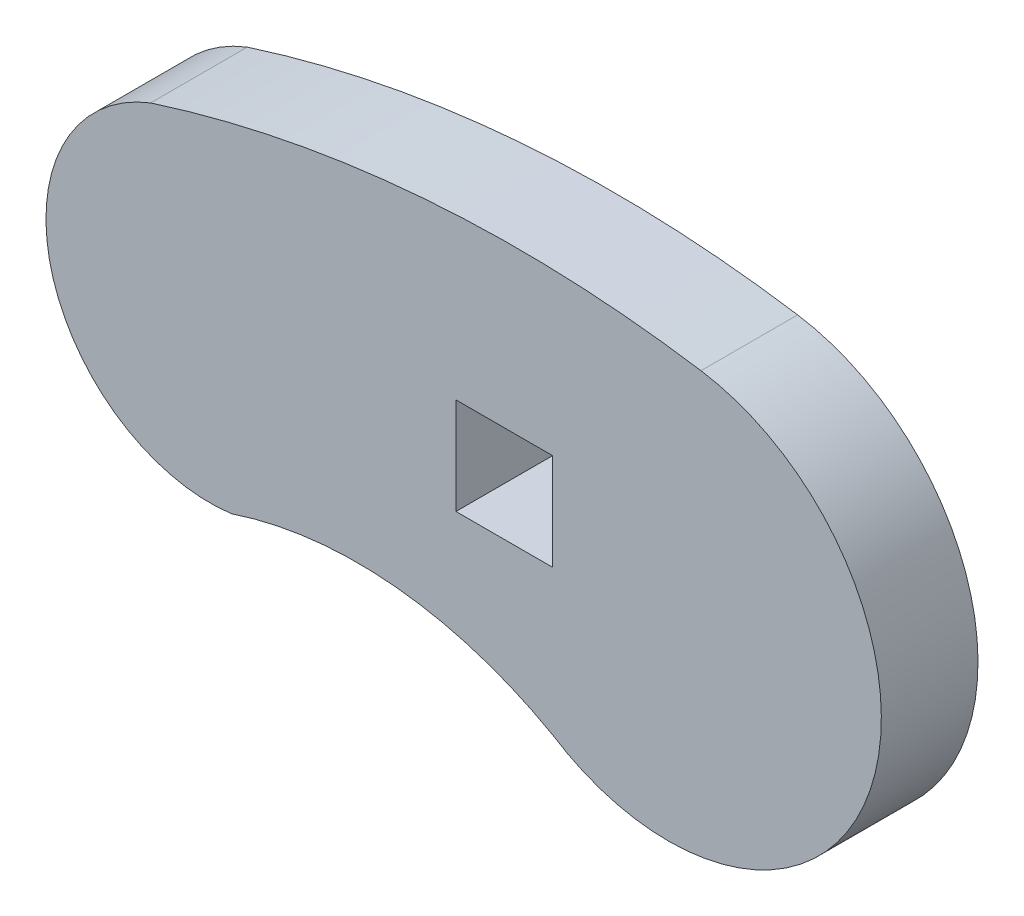
from build123d import *

# Parameters (mm, degrees)
SKETCH1_W           = 1.524
SKETCH1_H           = 1.524
BOSS_EXTRUDE1_DEPTH = 1.524


with BuildPart() as part:
    # Sketch1 → Boss-Extrude1 (new body)
    with BuildSketch(Plane.XY):
        with BuildLine():
            ThreePointArc((-4.813018271, 1.647414383), (-6.381436297, -1.405112195), (-3.535820464, -3.323529288))
            ThreePointArc((-3.535820464, -3.323529288), (-0.953914357, -3.028591374), (1.524, -3.811641797))
            ThreePointArc((1.524, -3.811641797), (6.486387953, -2.185545764), (3.86325293, 2.329832974))
            ThreePointArc((3.86325293, 2.329832974), (-0.514779052, 2.495866349), (-4.813018271, 1.647414383))
        make_face()
        with Locations((0.762, -0.762)):
            Rectangle(SKETCH1_W, SKETCH1_H, mode=Mode.SUBTRACT)
    extrude(amount=BOSS_EXTRUDE1_DEPTH)


solid = part.part
